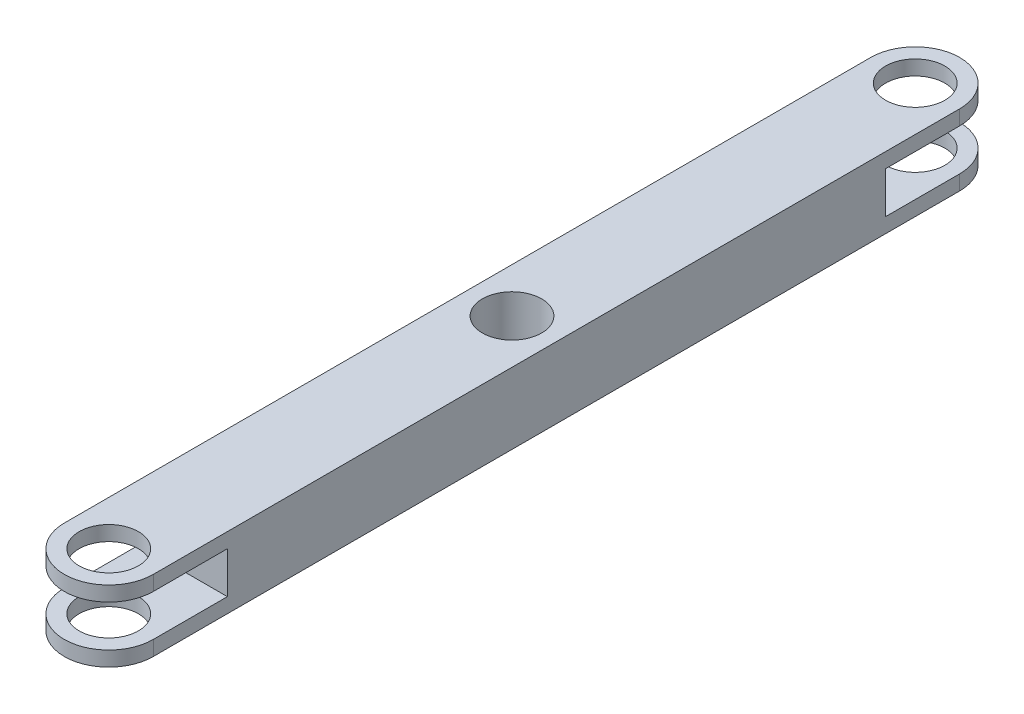
from build123d import *

# Parameters (mm, degrees)
CROQUIS1_R              = 2.5
SALIENTE_EXTRUIR1_DEPTH = 6
CROQUIS2_W              = 12.25
CROQUIS2_H              = 3.5
CORTAR_EXTRUIR1_DEPTH   = 7.5


with BuildPart() as part:
    # Croquis1 → Saliente-Extruir1 (new body)
    with BuildSketch(Plane(origin=(0, 0, 0), x_dir=(1, 0, 0), z_dir=(0, 1, 0))):
        with BuildLine():
            Line((-3.75, 34), (-3.75, -34))
            ThreePointArc((-3.75, -34), (0, -37.75), (3.75, -34))
            Line((3.75, -34), (3.75, 34))
            ThreePointArc((3.75, 34), (0, 37.75), (-3.75, 34))
        make_face()
        with Locations((0, 34)):
            Circle(CROQUIS1_R, mode=Mode.SUBTRACT)
        with Locations((0, -34)):
            Circle(CROQUIS1_R, mode=Mode.SUBTRACT)
        Circle(CROQUIS1_R, mode=Mode.SUBTRACT)
    extrude(amount=SALIENTE_EXTRUIR1_DEPTH)

    # Croquis2 → Cortar-Extruir1 (cut, symmetric)
    with BuildSketch(Plane(origin=(0, 0, 0), x_dir=(0, 0, -1), z_dir=(1, 0, 0))):
        with Locations((-33.875, 3)):
            Rectangle(CROQUIS2_W, CROQUIS2_H)
        with Locations((33.875, 3)):
            Rectangle(CROQUIS2_W, CROQUIS2_H)
    extrude(amount=CORTAR_EXTRUIR1_DEPTH, both=True, mode=Mode.SUBTRACT)


solid = part.part
